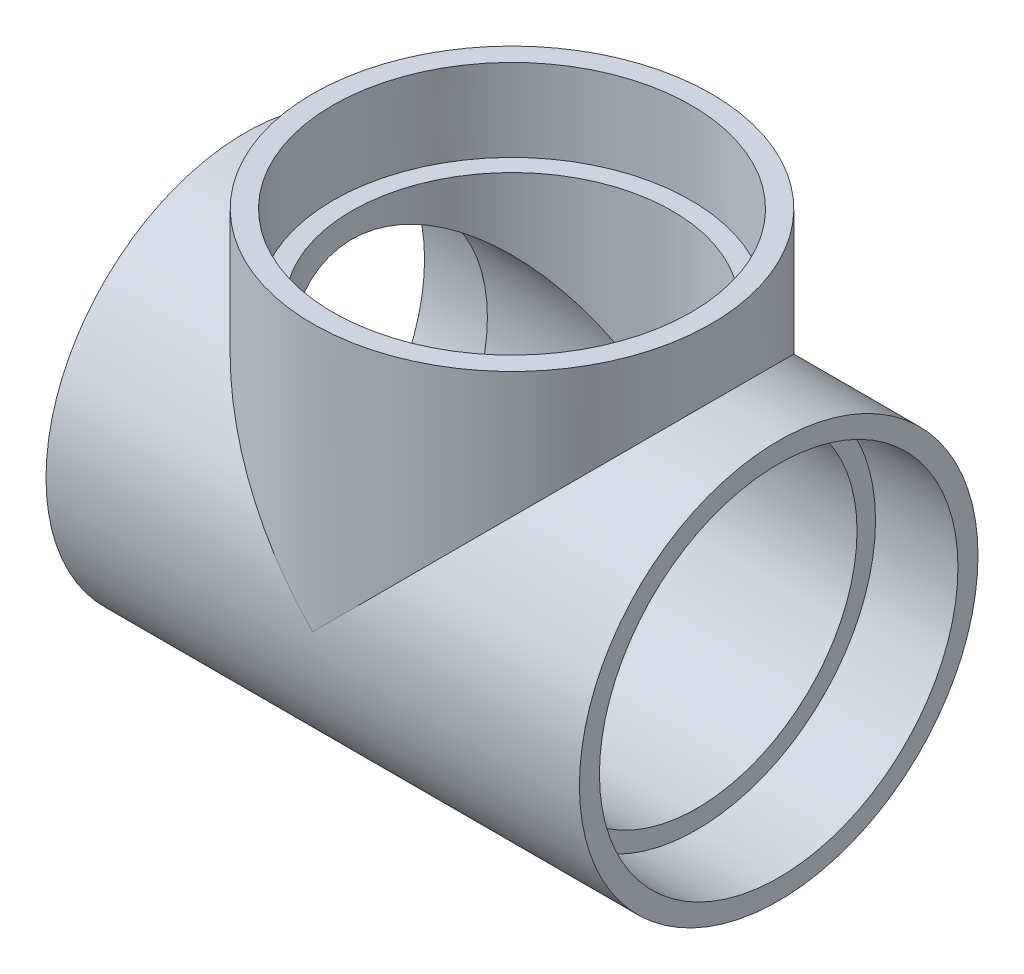
from build123d import *

# Parameters (mm, degrees)
SKETCH4_R           = 63.6016
BOSS_EXTRUDE1_DEPTH = 117.9576
SKETCH5_R           = 63.6016
BOSS_EXTRUDE2_DEPTH = 58.9788
SKETCH8_R           = 63.6016
SKETCH8_R_2         = 47.397505823
CUT_EXTRUDE1_DEPTH  = 25.4
SKETCH9_R           = 79.726534617
SKETCH9_R_2         = 24.880704632
CUT_EXTRUDE2_DEPTH  = 25.4
SKETCH10_R          = 82.836499496
SKETCH10_R_2        = 21.967276082
CUT_EXTRUDE3_DEPTH  = 25.4


with BuildPart() as part:
    # Sketch1 → Revolve1 (revolve)
    with BuildSketch(Plane.XY):
        Polygon((-110.5154, -63.6016), (-58.9788, -63.6016), (-58.9788, -57.0357), (-110.5154, -57.3786), align=None)
        Polygon((110.5154, -57.3786), (58.9788, -57.0357), (58.9788, -63.6016), (110.5154, -63.6016), align=None)
    revolve(axis=Axis((-110.5154, 0, 0), (1, 0, 0)))



with BuildPart() as body_2:
    # Sketch2 → Revolve2 (revolve)
    with BuildSketch(Plane.XY):
        Polygon((57.3786, 110.5154), (57.0357, 58.9788), (63.6016, 58.9788), (63.6016, 110.5154), align=None)
    revolve(axis=Axis((0, 0, 0), (0, 1, 0)))


with BuildPart() as part_1:
    add(part.part)

    add(body_2.part)  # Boss-Extrude1 merges body 2
    # Sketch4 → Boss-Extrude1 (add)
    with BuildSketch(Plane(origin=(-58.9788, 0, 0), x_dir=(0, 0, -1), z_dir=(1, 0, 0))):
        Circle(SKETCH4_R)
    extrude(amount=BOSS_EXTRUDE1_DEPTH)

    # Sketch5 → Boss-Extrude2 (add)
    with BuildSketch(Plane.XZ.offset(-58.9788)):
        Circle(SKETCH5_R)
    extrude(amount=BOSS_EXTRUDE2_DEPTH)

    # Sketch6 → Cut-Revolve1 (revolve, cut)
    with BuildSketch(Plane.XY):
        Polygon((-110.5154, -57.3786), (-58.9788, -57.0357), (-58.9788, -51.1302), (58.9788, -51.1302), (58.9788, -57.0357), (110.5154, -57.3786), (110.5154, 0), (-110.5154, 0), align=None)
    revolve(axis=Axis((110.5154, 0, 0), (-1, 0, 0)), mode=Mode.SUBTRACT)

    # Sketch7 → Cut-Revolve2 (revolve, cut)
    with BuildSketch(Plane.XY):
        Polygon((57.3786, 110.5154), (57.0357, 58.9788), (51.1302, 58.9788), (51.1302, 0), (0, 0), (0, 110.5154), align=None)
    revolve(axis=Axis((0, 0, 0), (0, 1, 0)), mode=Mode.SUBTRACT)

    # Sketch8 → Cut-Extrude1 (cut)
    with BuildSketch(Plane(origin=(0, 110.5154, 0), x_dir=(1, 0, 0), z_dir=(0, 1, 0))):
        Circle(SKETCH8_R)
        Circle(SKETCH8_R_2, mode=Mode.SUBTRACT)
    extrude(amount=-CUT_EXTRUDE1_DEPTH, mode=Mode.SUBTRACT)

    # Sketch9 → Cut-Extrude2 (cut)
    with BuildSketch(Plane.ZY.offset(110.5154)):
        Circle(SKETCH9_R)
        Circle(SKETCH9_R_2, mode=Mode.SUBTRACT)
    extrude(amount=-CUT_EXTRUDE2_DEPTH, mode=Mode.SUBTRACT)

    # Sketch10 → Cut-Extrude3 (cut)
    with BuildSketch(Plane(origin=(110.5154, 0, 0), x_dir=(0, 0, -1), z_dir=(1, 0, 0))):
        Circle(SKETCH10_R)
        Circle(SKETCH10_R_2, mode=Mode.SUBTRACT)
    extrude(amount=-CUT_EXTRUDE3_DEPTH, mode=Mode.SUBTRACT)


solid = part_1.part
